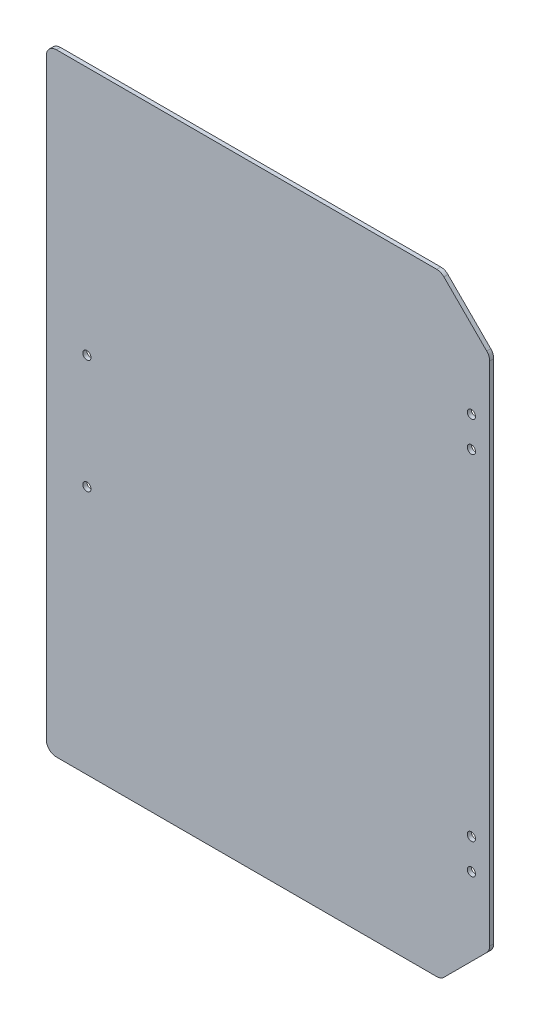
from build123d import *

# Parameters (mm, degrees)
SKETCH1_R           = 4.05
BOSS_EXTRUDE1_DEPTH = 4
FILLET1_R           = 10
SKETCH2_R           = 4.05
CUT_EXTRUDE1_DEPTH  = 4


with BuildPart() as part:
    # Sketch1 → Boss-Extrude1 (new body)
    with BuildSketch(Plane.XY):
        Polygon((198.355613631, 254.435441941), (198.355613631, -252.564558059), (150.355613631, -300.564558059), (-238.144386369, -300.564558059), (-238.144386369, 302.435441941), (150.355613631, 302.435441941), align=None)
        with Locations((180.355613631, 195.935441941)):
            Circle(SKETCH1_R, mode=Mode.SUBTRACT)
        with Locations((180.355613631, 165.935441941)):
            Circle(SKETCH1_R, mode=Mode.SUBTRACT)
        with Locations((180.355613631, -164.064558059)):
            Circle(SKETCH1_R, mode=Mode.SUBTRACT)
        with Locations((180.355613631, -194.064558059)):
            Circle(SKETCH1_R, mode=Mode.SUBTRACT)
    extrude(amount=BOSS_EXTRUDE1_DEPTH)

    # Fillet1
    fillet1_edges = [part.edges().sort_by_distance(p)[0] for p in [
        (-238.144386369, 302.435441941, 2),
        (150.355613631, 302.435441941, 2),
        (198.355613631, 254.435441941, 2),
        (198.355613631, -252.564558059, 2),
        (150.355613631, -300.564558059, 2),
        (-238.144386369, -300.564558059, 2),
    ]]
    fillet(fillet1_edges, radius=FILLET1_R)

    # Sketch2 → Cut-Extrude1 (cut)
    with BuildSketch(Plane.XY.offset(4)):
        with Locations((-198.144386369, 56.935441941)):
            Circle(SKETCH2_R)
        with Locations((-198.144386369, -55.064558059)):
            Circle(SKETCH2_R)
    extrude(amount=-CUT_EXTRUDE1_DEPTH, mode=Mode.SUBTRACT)


solid = part.part
